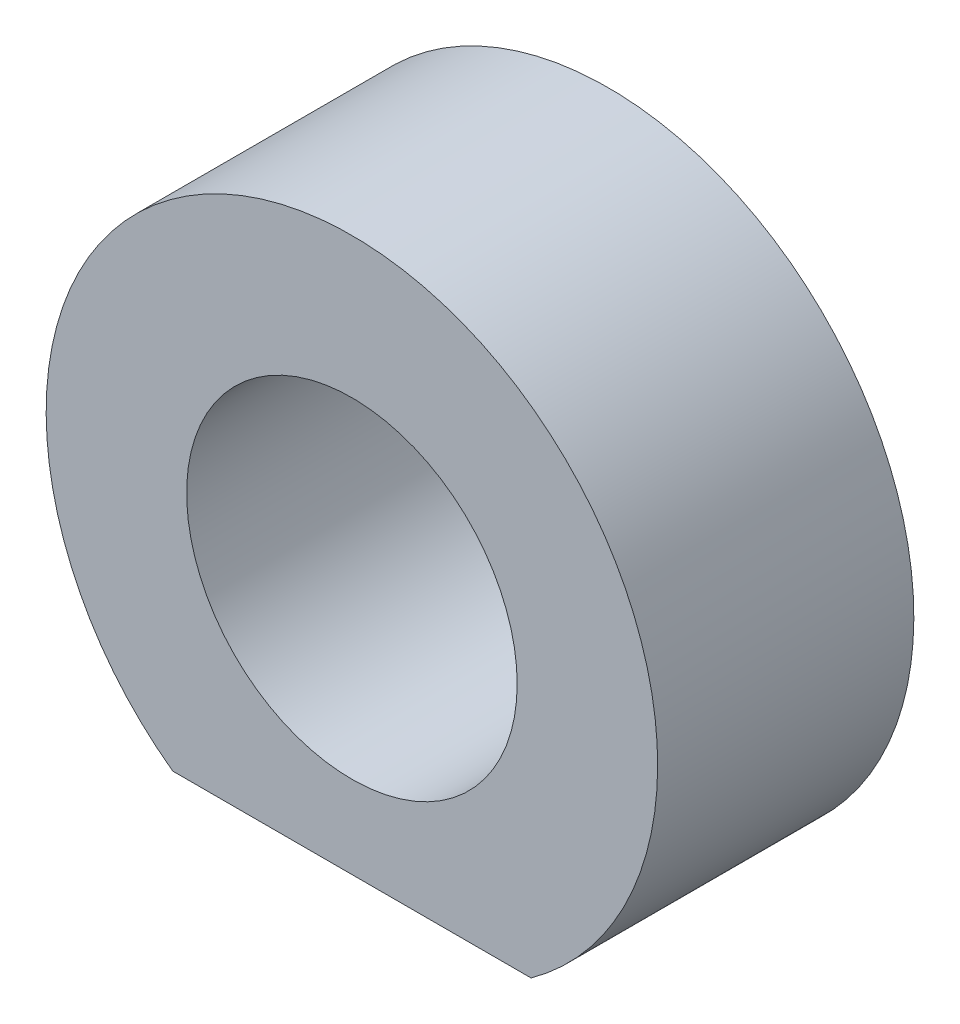
from build123d import *

# Parameters (mm, degrees)
SKETCH1_R           = 10
BOSS_EXTRUDE1_DEPTH = 15.5


with BuildPart() as part:
    # Sketch1 → Boss-Extrude1 (new body)
    with BuildSketch(Plane.XY):
        with BuildLine():
            Line((-10.842043165, -14.99), (10.842043165, -14.99))
            ThreePointArc((10.842043165, -14.99), (0, 18.5), (-10.842043165, -14.99))
        make_face()
        Circle(SKETCH1_R, mode=Mode.SUBTRACT)
    extrude(amount=BOSS_EXTRUDE1_DEPTH)


solid = part.part
